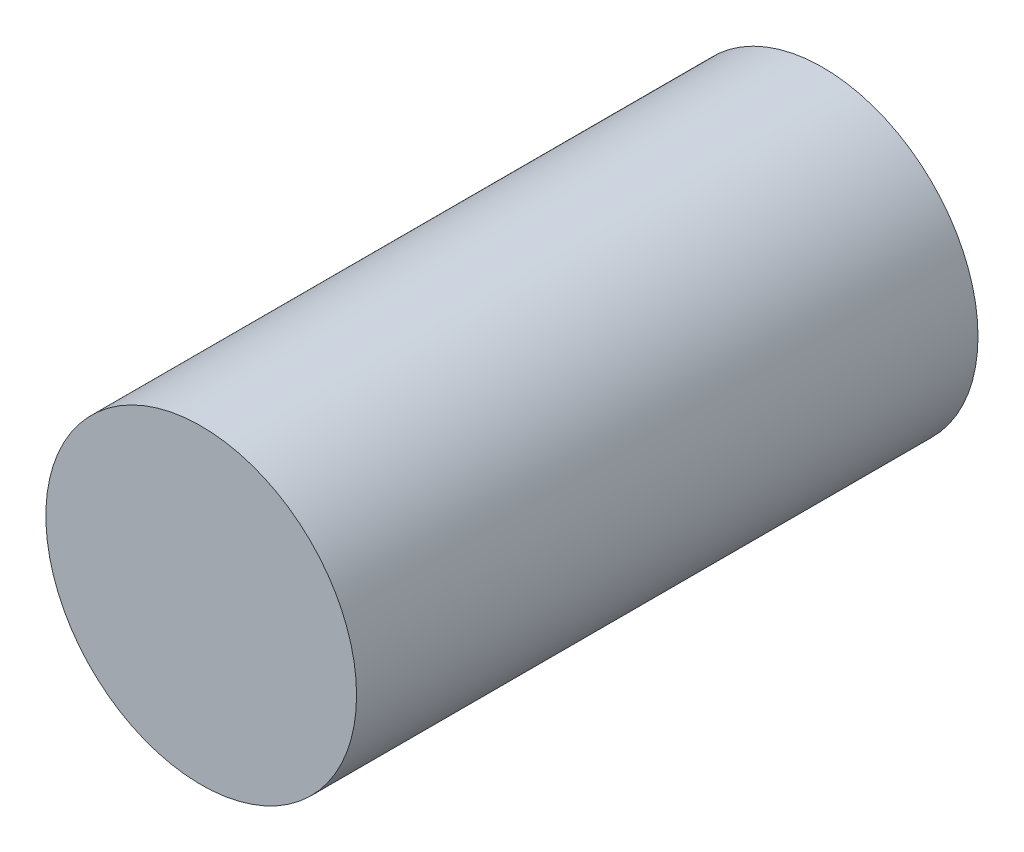
from build123d import *

# Parameters (mm, degrees)
SKETCH1_R           = 1.25
BOSS_EXTRUDE1_DEPTH = 5


with BuildPart() as part:
    # Sketch1 → Boss-Extrude1 (new body)
    with BuildSketch(Plane.XY):
        Circle(SKETCH1_R)
    extrude(amount=BOSS_EXTRUDE1_DEPTH)


solid = part.part
